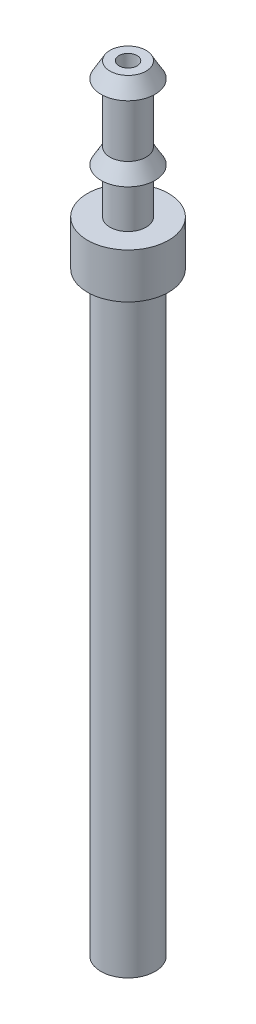
from build123d import *


with BuildPart() as part:
    # Эскиз1 → Повернуть1 (revolve)
    with BuildSketch(Plane.XY):
        Polygon((-1, -66), (-3, -66), (-3, 0), (-4.5, 0), (-4.5, 5), (-2, 5), (-2, 10), (-3, 10), (-2, 11.732050808), (-2, 18.267949192), (-3, 18.267949192), (-2, 20), (-1, 20), align=None)
    revolve(axis=Axis((0, 0, 0), (0, 1, 0)))


solid = part.part
